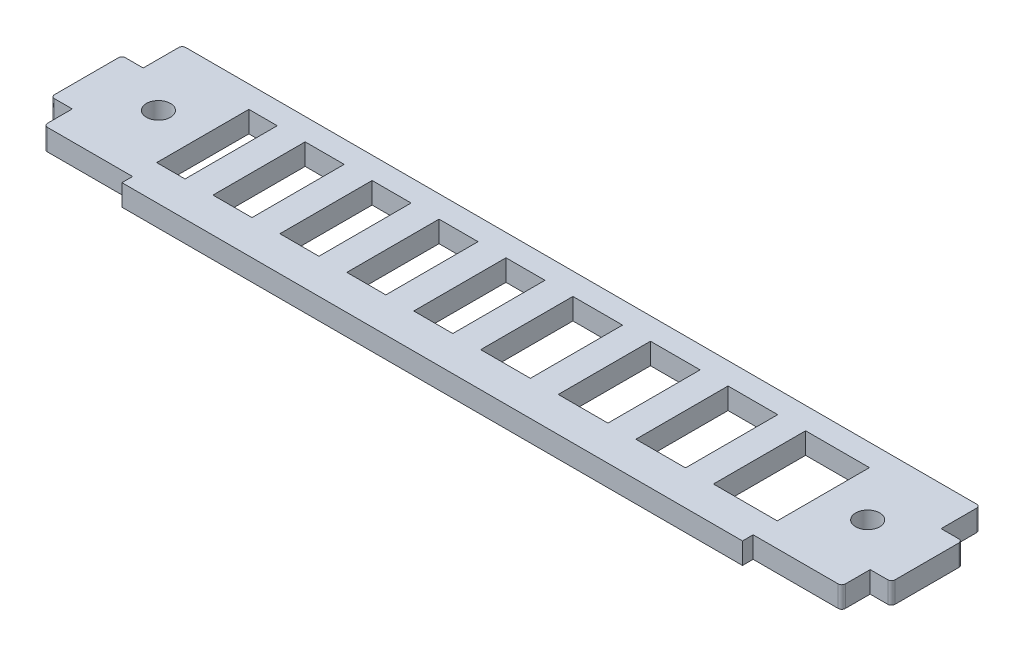
from build123d import *

# Parameters (mm, degrees)
SKETCH_1_W            = 5.5
SKETCH_1_H            = 13
SKETCH_1_W_2          = 7
SKETCH_1_W_3          = 4
SKETCH_1_W_4          = 9
EXTRUDE_1_DEPTH       = 3
HOLE_WIZARD_M31_D     = 3.4
HOLE_WIZARD_M31_DEPTH = 10
HOLE_WIZARD_M31_TIP   = 1.021463052
FILLET_1_R            = 0.5


with BuildPart() as part:
    # Эскиз1 → Бобышка-Вытянуть1 (new body)
    with BuildSketch(Plane(origin=(0, 0, 0), x_dir=(1, 0, 0), z_dir=(0, 1, 0))):
        Polygon((-43.75, -21), (43.75, -21), (43.75, -19.5), (56.25, -19.5), (56.25, -15.5), (59.25, -15.5), (59.25, -5.5), (56.25, -5.5), (56.25, 0), (-56.25, 0), (-56.25, -5.5), (-59.25, -5.5), (-59.25, -15.5), (-56.25, -15.5), (-56.25, -19.5), (-43.75, -19.5), align=None)
        with Locations((-23.625, -9.6)):
            Rectangle(SKETCH_1_W, SKETCH_1_H, mode=Mode.SUBTRACT)
        with Locations((-33.0625, -9.6)):
            Rectangle(SKETCH_1_W, SKETCH_1_H, mode=Mode.SUBTRACT)
        with Locations((-14.1875, -9.6)):
            Rectangle(SKETCH_1_W, SKETCH_1_H, mode=Mode.SUBTRACT)
        with Locations((-4.75, -9.6)):
            Rectangle(SKETCH_1_W, SKETCH_1_H, mode=Mode.SUBTRACT)
        with Locations((16.375, -9.6)):
            Rectangle(SKETCH_1_W_2, SKETCH_1_H, mode=Mode.SUBTRACT)
        with Locations((5.4375, -9.6)):
            Rectangle(SKETCH_1_W_2, SKETCH_1_H, mode=Mode.SUBTRACT)
        with Locations((27.3125, -9.6)):
            Rectangle(SKETCH_1_W_2, SKETCH_1_H, mode=Mode.SUBTRACT)
        with Locations((-41.75, -9.6)):
            Rectangle(SKETCH_1_W_3, SKETCH_1_H, mode=Mode.SUBTRACT)
        with Locations((39.25, -9.6)):
            Rectangle(SKETCH_1_W_4, SKETCH_1_H, mode=Mode.SUBTRACT)
    extrude(amount=EXTRUDE_1_DEPTH)

    # Отверстие с зазором M31
    with Locations(Plane(origin=(0, 3, 0), x_dir=(1, 0, 0), z_dir=(0, 1, 0))):
        with Locations((50, -9.6), (-50, -9.6)):
            Hole(HOLE_WIZARD_M31_D / 2, depth=HOLE_WIZARD_M31_DEPTH)
            with Locations((0, 0, -(HOLE_WIZARD_M31_DEPTH + HOLE_WIZARD_M31_TIP / 2))):  # 118° drill point
                Cone(0, HOLE_WIZARD_M31_D / 2, HOLE_WIZARD_M31_TIP, mode=Mode.SUBTRACT)

    # Скругление1
    fillet_1_edges = [part.edges().sort_by_distance(p)[0] for p in [
        (-56.25, 1.5, 19.5),
        (-59.25, 1.5, 15.5),
        (-59.25, 1.5, 5.5),
        (-56.25, 1.5, 0),
        (56.25, 1.5, 0),
        (59.25, 1.5, 5.5),
        (59.25, 1.5, 15.5),
        (56.25, 1.5, 19.5),
    ]]
    fillet(fillet_1_edges, radius=FILLET_1_R)


solid = part.part
